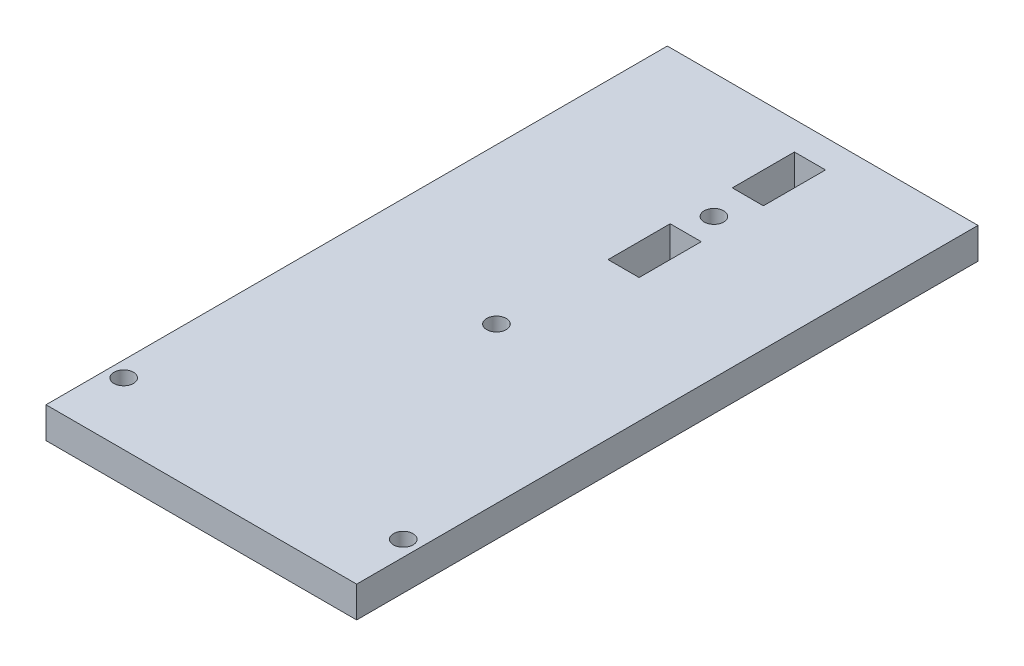
from build123d import *

# Parameters (mm, degrees)
SKETCH1_W           = 63.5
SKETCH1_H           = 127
SKETCH1_R           = 2
BOSS_EXTRUDE1_DEPTH = 6.35
SKETCH2_R           = 2
SKETCH2_W           = 6.35
SKETCH2_H           = 12.7
CUT_EXTRUDE1_DEPTH  = 6.35


with BuildPart() as part:
    # Sketch1 → Boss-Extrude1 (new body)
    with BuildSketch(Plane(origin=(0, 0, 0), x_dir=(1, 0, 0), z_dir=(0, 1, 0))):
        with Locations((31.75, 63.5)):
            Rectangle(SKETCH1_W, SKETCH1_H)
        with Locations((3.175, 12.7)):
            Circle(SKETCH1_R, mode=Mode.SUBTRACT)
        with Locations((60.325, 12.7)):
            Circle(SKETCH1_R, mode=Mode.SUBTRACT)
        with Locations((31.75, 60.325)):
            Circle(SKETCH1_R, mode=Mode.SUBTRACT)
    extrude(amount=BOSS_EXTRUDE1_DEPTH)

    # Sketch2 → Cut-Extrude1 (cut)
    with BuildSketch(Plane(origin=(0, 6.35, 0), x_dir=(1, 0, 0), z_dir=(0, 1, 0))):
        with Locations((34.925, 101.6)):
            Circle(SKETCH2_R)
        with Locations((34.925, 89.48002155)):
            Rectangle(SKETCH2_W, SKETCH2_H)
        with Locations((34.925, 114.88002155)):
            Rectangle(SKETCH2_W, SKETCH2_H)
    extrude(amount=-CUT_EXTRUDE1_DEPTH, mode=Mode.SUBTRACT)


solid = part.part
